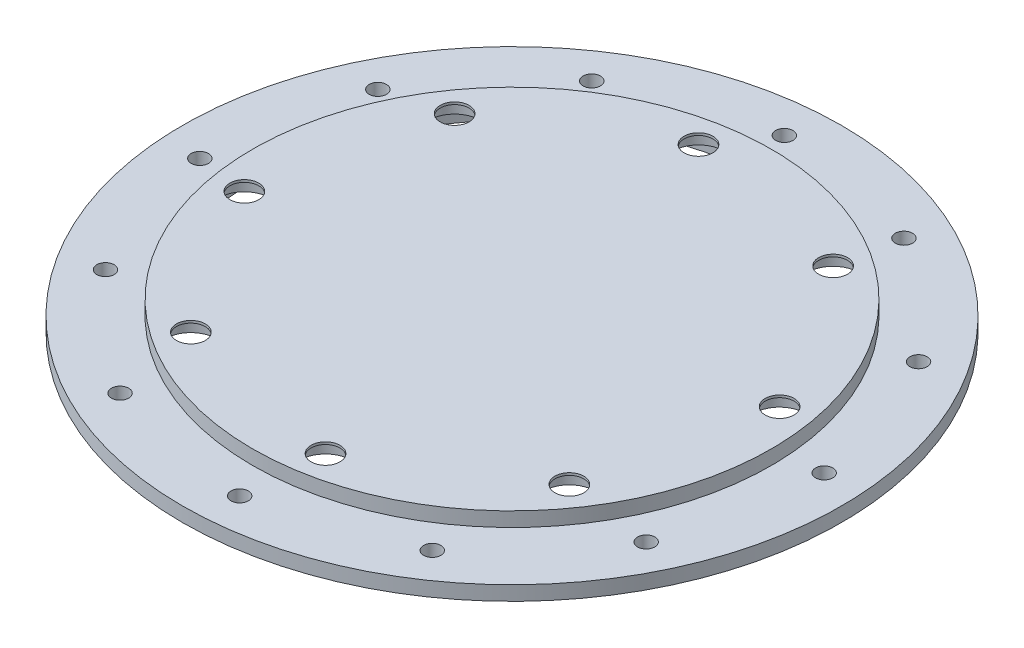
from build123d import *

# Parameters (mm, degrees)
SKETCH1_R                               = 114.3
BOSS_EXTRUDE1_DEPTH                     = 5
SKETCH2_R                               = 90
BOSS_EXTRUDE2_DEPTH                     = 5
SKETCH4_R                               = 90
CUT_EXTRUDE2_DEPTH                      = 3.5
F_6_0MM_DOWEL_HOLE1_D                   = 6
F_6_0MM_DOWEL_HOLE1_DEPTH               = 5
CIRPATTERN1_COUNT                       = 12
CBORE_FOR_M8_HEX_HEAD_BOLT2_D           = 10
CBORE_FOR_M8_HEX_HEAD_BOLT2_DEPTH       = 6.5
CBORE_FOR_M8_HEX_HEAD_BOLT2_CBORE_D     = 18.01
CBORE_FOR_M8_HEX_HEAD_BOLT2_CBORE_DEPTH = 5.68
CIRPATTERN2_COUNT                       = 8


with BuildPart() as part:
    # Sketch1 → Boss-Extrude1 (new body)
    with BuildSketch(Plane(origin=(0, 0, 0), x_dir=(1, 0, 0), z_dir=(0, 1, 0))):
        Circle(SKETCH1_R)
    extrude(amount=BOSS_EXTRUDE1_DEPTH)

    # Sketch2 → Boss-Extrude2 (add)
    with BuildSketch(Plane(origin=(0, 5, 0), x_dir=(1, 0, 0), z_dir=(0, 1, 0))):
        Circle(SKETCH2_R)
    extrude(amount=BOSS_EXTRUDE2_DEPTH)

    # Sketch4 → Cut-Extrude2 (cut)
    with BuildSketch(Plane(origin=(0, 0, 0), x_dir=(-1, 0, 0), z_dir=(0, -1, 0))):
        Circle(SKETCH4_R)
    extrude(amount=-CUT_EXTRUDE2_DEPTH, mode=Mode.SUBTRACT)

    # Ø6.0mm Dowel Hole1
    with Locations(Plane(origin=(0, 5, 0), x_dir=(1, 0, 0), z_dir=(0, 1, 0))):
        with Locations((-6.911227035, 101.364663176)):
            f_6_0mm_dowel_hole1 = Hole(F_6_0MM_DOWEL_HOLE1_D / 2, depth=F_6_0MM_DOWEL_HOLE1_DEPTH)

    # CirPattern1: Ø6.0mm Dowel Hole1 ×12 about axis
    cirpattern1_axis = Axis((0, 0, 0), (0, 1, 0))
    for i in range(1, CIRPATTERN1_COUNT):
        add(f_6_0mm_dowel_hole1.rotate(cirpattern1_axis, i * 360 / CIRPATTERN1_COUNT), mode=Mode.SUBTRACT)

    # CBORE for M8 Hex Head Bolt2
    with Locations(Plane(origin=(0, 3.5, 0), x_dir=(-1, 0, 0), z_dir=(0, -1, 0))):
        with Locations((-45.734775632, 65.637872435)):
            cbore_for_m8_hex_head_bolt2 = CounterBoreHole(CBORE_FOR_M8_HEX_HEAD_BOLT2_D / 2, CBORE_FOR_M8_HEX_HEAD_BOLT2_CBORE_D / 2, CBORE_FOR_M8_HEX_HEAD_BOLT2_CBORE_DEPTH, depth=CBORE_FOR_M8_HEX_HEAD_BOLT2_DEPTH)

    # CirPattern2: CBORE for M8 Hex Head Bolt2 ×8 about axis
    cirpattern2_axis = Axis((0, 0, 0), (0, 1, 0))
    for i in range(1, CIRPATTERN2_COUNT):
        add(cbore_for_m8_hex_head_bolt2.rotate(cirpattern2_axis, i * 360 / CIRPATTERN2_COUNT), mode=Mode.SUBTRACT)


solid = part.part
